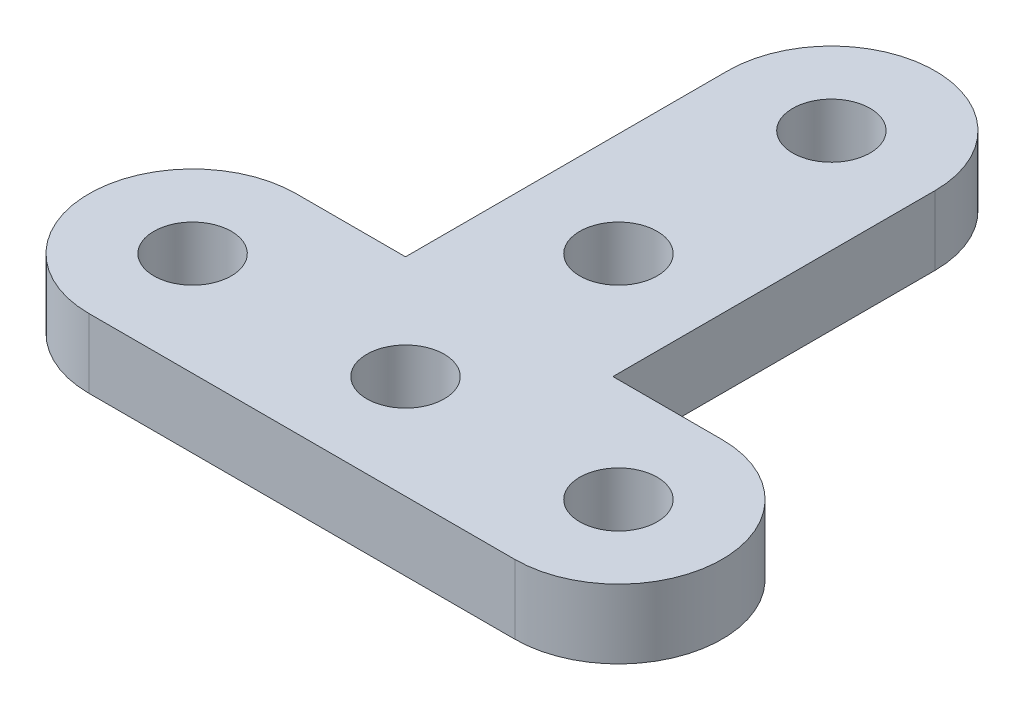
from build123d import *

# Parameters (mm, degrees)
SKETCH1_R           = 1.778
BOSS_EXTRUDE1_DEPTH = 3.175


with BuildPart() as part:
    # Sketch1 → Boss-Extrude1 (new body)
    with BuildSketch(Plane(origin=(0, 3.175, 0), x_dir=(1, 0, 0), z_dir=(0, 1, 0))):
        with BuildLine():
            Line((4.7625, 4.7625), (4.7625, 19.558))
            ThreePointArc((4.7625, 19.558), (0, 24.3205), (-4.7625, 19.558))
            Line((-4.7625, 19.558), (-4.7625, 4.7625))
            Line((-4.7625, 4.7625), (-9.779, 4.7625))
            ThreePointArc((-9.779, 4.7625), (-14.5415, 0), (-9.779, -4.7625))
            Line((-9.779, -4.7625), (9.779, -4.7625))
            ThreePointArc((9.779, -4.7625), (14.5415, 0), (9.779, 4.7625))
            Line((9.779, 4.7625), (4.7625, 4.7625))
        make_face()
        with Locations((0, 19.558)):
            Circle(SKETCH1_R, mode=Mode.SUBTRACT)
        with Locations((9.779, 0)):
            Circle(SKETCH1_R, mode=Mode.SUBTRACT)
        with Locations((0, 9.779)):
            Circle(SKETCH1_R, mode=Mode.SUBTRACT)
        with Locations((-9.779, 0)):
            Circle(SKETCH1_R, mode=Mode.SUBTRACT)
        Circle(SKETCH1_R, mode=Mode.SUBTRACT)
    extrude(amount=-BOSS_EXTRUDE1_DEPTH)


solid = part.part
